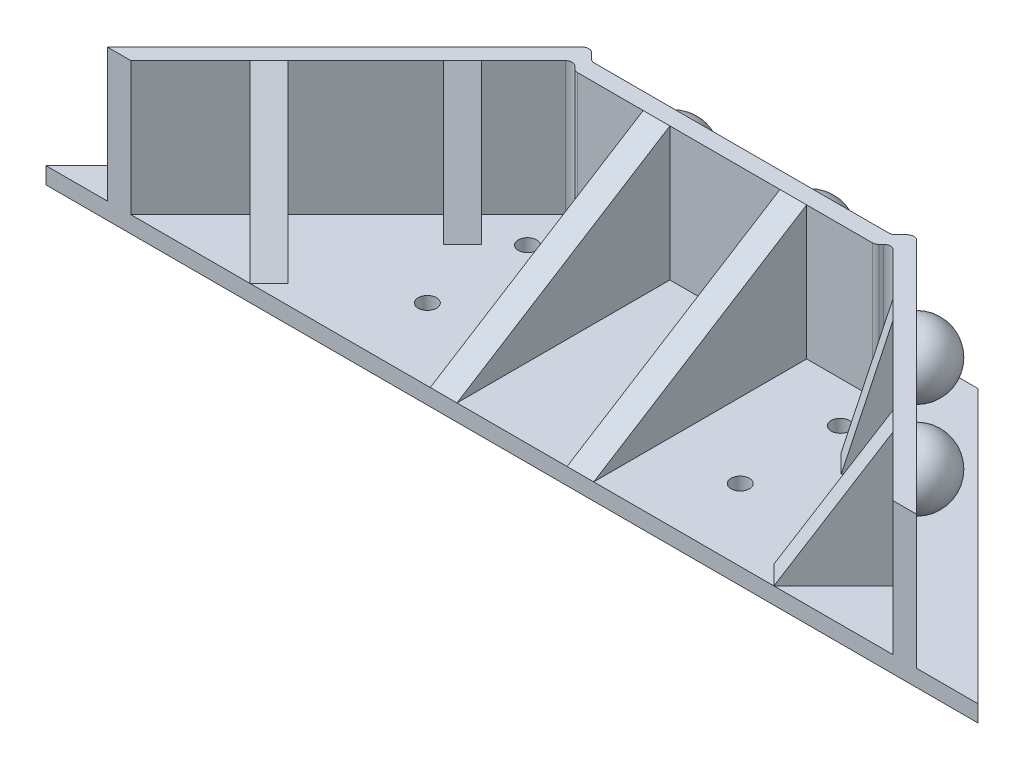
from build123d import *

# Parameters (mm, degrees)
BRACKETBASE_DEPTH        = 2.5
SKETCH3_R                = 1.375
MOUNTINGHOLES_DEPTH      = 1
MOUNTINGHOLES_DEPTH_BACK = 3.5
BALLMOUNTPRESSURE_W      = 45
BALLMOUNTPRESSURE_H      = 2.5
BALLPRESSUREWALLS_DEPTH  = 27.47538085
BALL1_ANGLE              = 180
BALL2_ANGLE              = 180
BALL3_ANGLE              = 180
REVOLVE4_ANGLE           = 180
REVOLVE5_ANGLE           = 180
REVOLVE6_ANGLE           = 180
BOSS_EXTRUDE2_DEPTH      = 27.475381
FILLET1_R                = 1
SKETCH11_W               = 5
SKETCH11_H               = 31.91718267
BOSS_EXTRUDE3_DEPTH      = 27.475381
CUT_EXTRUDE1_DEPTH       = 47.632564804
CUT_EXTRUDE2_DEPTH       = 28.447536
CUT_EXTRUDE3_DEPTH       = 25.5
SKETCH15_W               = 50.154642736
SKETCH15_H               = 7.47538085
CUT_EXTRUDE4_DEPTH       = 10
SKETCH16_W               = 54.765129608
SKETCH16_H               = 7.47538085
CUT_EXTRUDE5_DEPTH       = 38.932817333
SKETCH17_W               = 54.765129607
SKETCH17_H               = 7.47538085
CUT_EXTRUDE6_DEPTH       = 38.932817333
CUT_EXTRUDE7_DEPTH       = 25.5
CUT_EXTRUDE8_DEPTH       = 28.447536
CUT_EXTRUDE9_DEPTH       = 25.5
SKETCH22_W               = 4
SKETCH22_H               = 34.41718267
BOSS_EXTRUDE4_DEPTH      = 20
CUT_EXTRUDE10_DEPTH      = 24.5
CUT_EXTRUDE11_DEPTH      = 4
CUT_EXTRUDE12_DEPTH      = 4
CUT_EXTRUDE13_DEPTH      = 4
CUT_EXTRUDE14_DEPTH      = 4
BOSS_EXTRUDE5_DEPTH      = 2.5


with BuildPart() as part:
    # Sketch2 → bracketBase (new body)
    with BuildSketch(Plane(origin=(0, 0, 0), x_dir=(1, 0, 0), z_dir=(0, 1, 0))):
        Polygon((0, 0), (40.91718267, 40.91718267), (98.78281733, 40.91718267), (139.7, 0), align=None)
    extrude(amount=BRACKETBASE_DEPTH)

    # Sketch3 → mountingHoles (cut, two sides)
    with BuildSketch(Plane(origin=(0, 2.5, 0), x_dir=(1, 0, 0), z_dir=(0, 1, 0))) as mountingholes_sk:
        with Locations((8.01021217, 3.76757148)):
            Circle(SKETCH3_R)
        with Locations((15.54535513, 11.30271444)):
            Circle(SKETCH3_R)
        with Locations((46.40246404, 25.75962576)):
            Circle(SKETCH3_R)
        with Locations((46.40246404, 10.75962576)):
            Circle(SKETCH3_R)
        with Locations((93.29753596, 10.75962576)):
            Circle(SKETCH3_R)
        with Locations((93.29753596, 25.75962576)):
            Circle(SKETCH3_R)
        with Locations((124.15464487, 11.30271444)):
            Circle(SKETCH3_R)
        with Locations((131.68978783, 3.76757148)):
            Circle(SKETCH3_R)
    extrude(amount=MOUNTINGHOLES_DEPTH, mode=Mode.SUBTRACT)
    extrude(mountingholes_sk.sketch, amount=-MOUNTINGHOLES_DEPTH_BACK, mode=Mode.SUBTRACT)

    # ballMountPressure → ballPressureWalls (add)
    with BuildSketch(Plane(origin=(0, 2.5, 0), x_dir=(1, 0, 0), z_dir=(0, 1, 0))):
        Polygon((12.644882838, 3.452494682), (44.464687991, 35.272299836), (46.232454944, 33.504532883), (14.412649791, 1.684727729), align=None)
        Polygon((125.287350209, 1.684727729), (93.467545056, 33.504532883), (95.235312009, 35.272299836), (127.055117162, 3.452494682), align=None)
        with Locations((69.85, 33.16718267)):
            Rectangle(BALLMOUNTPRESSURE_W, BALLMOUNTPRESSURE_H)
    extrude(amount=BALLPRESSUREWALLS_DEPTH)

    # Sketch4 → ball1 (revolve)
    with BuildSketch(Plane(origin=(0, 0, -34.41718267), x_dir=(-1, 0, 0), z_dir=(0, 0, -1))):
        with BuildLine():
            Line((-80.1, 21.237690425), (-80.1, 11.237690425))
            ThreePointArc((-80.1, 11.237690425), (-75.1, 16.237690425), (-80.1, 21.237690425))
        make_face()
    revolve(axis=Axis((80.1, 21.237690425, -34.41718267), (0, -1, 0)), revolution_arc=BALL1_ANGLE)

    # Sketch5 → ball2 (revolve)
    with BuildSketch(Plane(origin=(0, 0, -34.41718267), x_dir=(-1, 0, 0), z_dir=(0, 0, -1))):
        with BuildLine():
            Line((-59.6, 21.237690425), (-59.6, 11.237690425))
            ThreePointArc((-59.6, 11.237690425), (-54.6, 16.237690425), (-59.6, 21.237690425))
        make_face()
    revolve(axis=Axis((59.6, 21.237690425, -34.41718267), (0, -1, 0)), revolution_arc=BALL2_ANGLE)

    # Sketch6 → ball3 (revolve)
    with BuildSketch(Plane(origin=(65.253805922, 0, -65.253805922), x_dir=(-0.707106781, 0, -0.707106781), z_dir=(0.707106781, 0, -0.707106781))):
        with BuildLine():
            Line((-75.150252528, 21.237690425), (-75.150252528, 11.237690425))
            ThreePointArc((-75.150252528, 11.237690425), (-70.150252528, 16.237690425), (-75.150252528, 21.237690425))
        make_face()
    revolve(axis=Axis((118.393059093, 21.237690425, -12.114552752), (0, -1, 0)), revolution_arc=BALL3_ANGLE)

    # Sketch7 → Revolve4 (revolve)
    with BuildSketch(Plane(origin=(65.253805922, 0, -65.253805922), x_dir=(-0.707106781, 0, -0.707106781), z_dir=(0.707106781, 0, -0.707106781))):
        with BuildLine():
            Line((-54.650252528, 21.237690425), (-54.650252528, 11.237690425))
            ThreePointArc((-54.650252528, 11.237690425), (-49.650252528, 16.237690425), (-54.650252528, 21.237690425))
        make_face()
    revolve(axis=Axis((103.897370078, 21.237690425, -26.610241766), (0, -1, 0)), revolution_arc=REVOLVE4_ANGLE)

    # Sketch8 → Revolve5 (revolve)
    with BuildSketch(Plane(origin=(4.596194078, 0, 4.596194078), x_dir=(-0.707106781, 0, 0.707106781), z_dir=(-0.707106781, 0, -0.707106781))):
        with BuildLine():
            Line((-23.632564804, 21.237690425), (-23.632564804, 11.237690425))
            ThreePointArc((-23.632564804, 11.237690425), (-18.632564804, 16.237690425), (-23.632564804, 21.237690425))
        make_face()
    revolve(axis=Axis((21.306940907, 21.237690425, -12.114552752), (0, -1, 0)), revolution_arc=REVOLVE5_ANGLE)

    # Sketch9 → Revolve6 (revolve)
    with BuildSketch(Plane(origin=(4.596194078, 0, 4.596194078), x_dir=(-0.707106781, 0, 0.707106781), z_dir=(-0.707106781, 0, -0.707106781))):
        with BuildLine():
            Line((-44.132564804, 21.237690425), (-44.132564804, 11.237690425))
            ThreePointArc((-44.132564804, 11.237690425), (-39.132564804, 16.237690425), (-44.132564804, 21.237690425))
        make_face()
    revolve(axis=Axis((35.802629922, 21.237690425, -26.610241766), (0, -1, 0)), revolution_arc=REVOLVE6_ANGLE)

    # Sketch10 → Boss-Extrude2 (add)
    with BuildSketch(Plane(origin=(0, 29.97538085, 0), x_dir=(1, 0, 0), z_dir=(0, 1, 0))):
        Polygon((47.35, 31.91718267), (45.997552366, 33.269630304), (44.229785413, 35.037397257), (45.479785413, 36.287397257), (47.35, 34.41718267), align=None)
        Polygon((14.412649791, 1.684727729), (12.727922061, 0), (9.192388155, 0), (12.644882838, 3.452494682), align=None)
        Polygon((92.35, 34.41718267), (94.220214587, 36.287397257), (95.470214587, 35.037397257), (93.702447634, 33.269630304), (92.35, 31.91718267), align=None)
        Polygon((130.507611845, 0), (127.055117162, 3.452494682), (125.287350209, 1.684727729), (126.972077939, 0), align=None)
    extrude(amount=-BOSS_EXTRUDE2_DEPTH)

    # Fillet1
    fillet1_edges = [part.edges().sort_by_distance(p)[0] for p in [
        (45.997552366, 16.237690425, -33.269630304),
        (45.479785413, 16.23769035, -36.287397257),
        (94.220214587, 16.23769035, -36.287397257),
        (93.702447634, 16.237690425, -33.269630304),
        (47.35, 16.237690425, -34.41718267),
        (47.35, 16.237690425, -31.91718267),
        (92.35, 16.237690425, -31.91718267),
        (92.35, 16.237690425, -34.41718267),
    ]]
    fillet(fillet1_edges, radius=FILLET1_R)

    # Sketch11 → Boss-Extrude3 (add)
    with BuildSketch(Plane(origin=(0, 29.97538085, 0), x_dir=(1, 0, 0), z_dir=(0, 1, 0))):
        with Locations((58.12623202, 15.958591335)):
            Rectangle(SKETCH11_W, SKETCH11_H)
        with Locations((81.57376798, 15.958591335)):
            Rectangle(SKETCH11_W, SKETCH11_H)
        Polygon((35.802629922, 23.07470786), (44.381648767, 14.495689014), (47.917182673, 18.03122292), (39.338163828, 26.610241766), align=None)
        Polygon((21.306940907, 8.579018846), (24.842474813, 12.114552752), (33.421493659, 3.535533906), (29.885959753, 0), align=None)
        Polygon((109.814040247, 0), (106.278506341, 3.535533906), (114.857525187, 12.114552752), (118.393059093, 8.579018846), align=None)
        Polygon((91.782817327, 18.03122292), (100.361836172, 26.610241766), (103.897370078, 23.07470786), (95.318351233, 14.495689014), align=None)
    extrude(amount=-BOSS_EXTRUDE3_DEPTH)

    # Sketch12 → Cut-Extrude1 (cut, through all)
    with BuildSketch(Plane(origin=(32.974202797, 0, -32.974202797), x_dir=(-0.707106781, 0, -0.707106781), z_dir=(0.707106781, 0, -0.707106781))):
        Polygon((-9, 29.97538085), (-21.132564804, 2.5), (-21.132564804, 29.97538085), align=None)
    extrude(amount=-CUT_EXTRUDE1_DEPTH, mode=Mode.SUBTRACT)

    # Sketch13 → Cut-Extrude2 (cut)
    with BuildSketch(Plane.ZY.offset(-55.62623202)):
        Polygon((-31.91718267, 29.97538085), (0, 2.5), (0, 29.97538085), align=None)
    extrude(amount=-CUT_EXTRUDE2_DEPTH, mode=Mode.SUBTRACT)

    # Sketch14 → Cut-Extrude3 (cut)
    with BuildSketch(Plane(origin=(54.907020123, 0, 54.907020123), x_dir=(0.707106781, 0, -0.707106781), z_dir=(0.707106781, 0, 0.707106781))):
        Polygon((77.650252528, 2.5), (89.782817332, 29.97538085), (77.650252528, 29.97538085), align=None)
    extrude(amount=-CUT_EXTRUDE3_DEPTH, mode=Mode.SUBTRACT)

    # Sketch15 → Cut-Extrude4 (cut, through all)
    with BuildSketch(Plane.XY.offset(-31.91718267)):
        with Locations((69.85, 26.237690425)):
            Rectangle(SKETCH15_W, SKETCH15_H)
    extrude(amount=-CUT_EXTRUDE4_DEPTH, mode=Mode.SUBTRACT)

    # Sketch16 → Cut-Extrude5 (cut, through all)
    with BuildSketch(Plane(origin=(63.486038969, 0, -63.486038969), x_dir=(0.707106781, 0, 0.707106781), z_dir=(-0.707106781, 0, 0.707106781))):
        with Locations((64.900252528, 26.237690425)):
            Rectangle(SKETCH16_W, SKETCH16_H)
    extrude(amount=-CUT_EXTRUDE5_DEPTH, mode=Mode.SUBTRACT)

    # Sketch17 → Cut-Extrude6 (cut, through all)
    with BuildSketch(Plane(origin=(6.363961031, 0, 6.363961031), x_dir=(0.707106781, 0, -0.707106781), z_dir=(0.707106781, 0, 0.707106781))):
        with Locations((33.882564804, 26.237690425)):
            Rectangle(SKETCH17_W, SKETCH17_H)
    extrude(amount=-CUT_EXTRUDE6_DEPTH, mode=Mode.SUBTRACT)

    # Sketch19 → Cut-Extrude7 (cut)
    with BuildSketch(Plane(origin=(14.942979877, 0, -14.942979877), x_dir=(0.707106781, 0, 0.707106781), z_dir=(-0.707106781, 0, 0.707106781))):
        Polygon((21.132564804, 2.5), (9, 29.97538085), (9, 22.5), (9, 2.5), align=None)
    extrude(amount=-CUT_EXTRUDE7_DEPTH, mode=Mode.SUBTRACT)

    # Sketch20 → Cut-Extrude8 (cut)
    with BuildSketch(Plane.ZY.offset(-55.62623202)):
        Polygon((0, 2.5), (-31.91718267, 29.97538085), (-31.91718267, 22.5), (-31.91718267, 2.5), align=None)
    extrude(amount=-CUT_EXTRUDE8_DEPTH, mode=Mode.SUBTRACT)

    # Sketch21 → Cut-Extrude9 (cut)
    with BuildSketch(Plane(origin=(54.907020123, 0, 54.907020123), x_dir=(0.707106781, 0, -0.707106781), z_dir=(0.707106781, 0, 0.707106781))):
        Polygon((89.782817332, 29.97538085), (77.650252528, 2.5), (89.782817332, 2.5), (89.782817332, 22.5), align=None)
    extrude(amount=-CUT_EXTRUDE9_DEPTH, mode=Mode.SUBTRACT)

    # Sketch22 → Boss-Extrude4 (add)
    with BuildSketch(Plane(origin=(0, 22.5, 0), x_dir=(1, 0, 0), z_dir=(0, 1, 0))):
        with Locations((59.6, 17.208591335)):
            Rectangle(SKETCH22_W, SKETCH22_H)
        Polygon((19.892727345, 10.700339189), (30.593066534, 0), (33.421493659, 2.828427125), (22.72115447, 13.528766314), align=None)
        with Locations((80.1, 17.208591335)):
            Rectangle(SKETCH22_W, SKETCH22_H)
        Polygon((34.388416359, 25.196028204), (37.216843484, 28.024455329), (42.873697733, 22.367601079), (40.045270609, 19.539173954), align=None)
        Polygon((105.311583641, 25.196028204), (102.483156516, 28.024455329), (96.826302267, 22.367601079), (99.654729391, 19.539173954), align=None)
        Polygon((119.807272655, 10.700339189), (116.97884553, 13.528766314), (106.278506341, 2.828427125), (109.106933466, 0), align=None)
    extrude(amount=-BOSS_EXTRUDE4_DEPTH)

    # Sketch23 → Cut-Extrude10 (cut)
    with BuildSketch(Plane.ZY.offset(-57.6)):
        Polygon((-31.91718267, 22.5), (0, 2.5), (0, 22.5), align=None)
    extrude(amount=-CUT_EXTRUDE10_DEPTH, mode=Mode.SUBTRACT)

    # Sketch24 → Cut-Extrude11 (cut)
    with BuildSketch(Plane(origin=(15.296533267, 0, -15.296533267), x_dir=(0.707106781, 0, 0.707106781), z_dir=(-0.707106781, 0, 0.707106781))):
        Polygon((9, 22.5), (21.632564804, 2.5), (21.632564804, 22.5), align=None)
    extrude(amount=-CUT_EXTRUDE11_DEPTH, mode=Mode.SUBTRACT)

    # Sketch25 → Cut-Extrude12 (cut)
    with BuildSketch(Plane(origin=(54.553466733, 0, 54.553466733), x_dir=(0.707106781, 0, -0.707106781), z_dir=(0.707106781, 0, 0.707106781))):
        Polygon((89.782817332, 22.5), (77.150252528, 2.5), (77.150252528, 22.5), align=None)
    extrude(amount=-CUT_EXTRUDE12_DEPTH, mode=Mode.SUBTRACT)

    # Sketch26 → Cut-Extrude13 (cut)
    with BuildSketch(Plane(origin=(29.792222281, 0, -29.792222281), x_dir=(0.707106781, 0, 0.707106781), z_dir=(-0.707106781, 0, 0.707106781))):
        Polygon((9, 22.5), (14.5, 22.5), (14.5, 2.5), align=None)
    extrude(amount=-CUT_EXTRUDE13_DEPTH, mode=Mode.SUBTRACT)

    # Sketch27 → Cut-Extrude14 (cut)
    with BuildSketch(Plane(origin=(40.057777719, 0, 40.057777719), x_dir=(0.707106781, 0, -0.707106781), z_dir=(0.707106781, 0, 0.707106781))):
        Polygon((84.282817332, 22.5), (89.782817332, 22.5), (84.282817332, 2.5), align=None)
    extrude(amount=-CUT_EXTRUDE14_DEPTH, mode=Mode.SUBTRACT)

    # Sketch28 → Boss-Extrude5 (add)
    with BuildSketch(Plane(origin=(0, 2.5, 0), x_dir=(1, 0, 0), z_dir=(0, 1, 0))):
        with BuildLine():
            Line((46.186892194, 35.580290476), (47.057106781, 34.710075889))
            ThreePointArc((47.057106781, 34.710075889), (47.38153013, 34.493303137), (47.764213562, 34.41718267))
            Line((47.764213562, 34.41718267), (91.935786438, 34.41718267))
            ThreePointArc((91.935786438, 34.41718267), (92.31846987, 34.493303137), (92.642893219, 34.710075889))
            Line((92.642893219, 34.710075889), (93.513107806, 35.580290476))
            ThreePointArc((93.513107806, 35.580290476), (94.220214587, 35.873183695), (94.927321368, 35.580290476))
            Line((94.927321368, 35.580290476), (130.507611845, 0))
            Line((130.507611845, 0), (139.7, 0))
            Line((139.7, 0), (98.78281733, 40.91718267))
            Line((98.78281733, 40.91718267), (40.91718267, 40.91718267))
            Line((40.91718267, 40.91718267), (0, 0))
            Line((0, 0), (9.192388155, 0))
            Line((9.192388155, 0), (44.772678632, 35.580290476))
            ThreePointArc((44.772678632, 35.580290476), (45.479785413, 35.873183695), (46.186892194, 35.580290476))
        make_face()
    extrude(amount=-BOSS_EXTRUDE5_DEPTH)


solid = part.part
